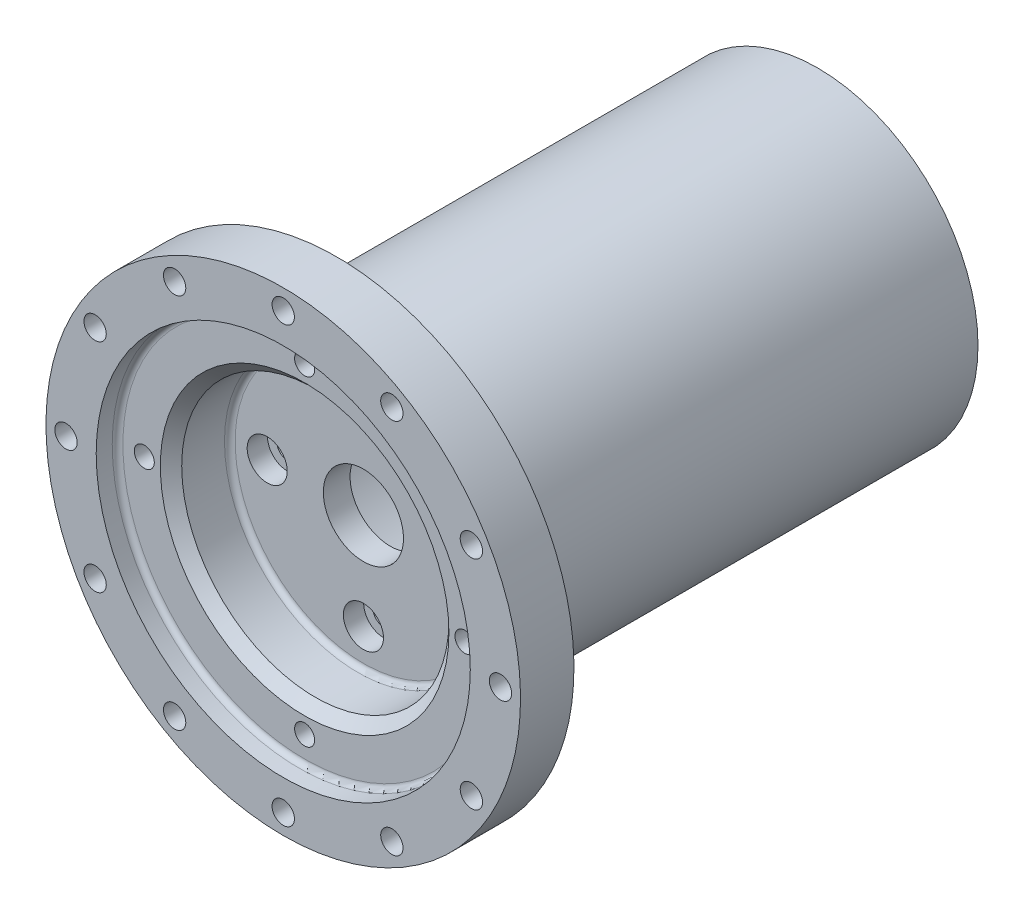
from build123d import *

# Parameters (mm, degrees)
SKETCH2_R                                       = 31.75
CUT_EXTRUDE1_DEPTH                              = 101.6
SKETCH3_R                                       = 31.75
CUT_EXTRUDE2_DEPTH                              = 19.05
SKETCH4_R                                       = 9.525
CUT_EXTRUDE3_DEPTH                              = 108.95
SKETCH5_R                                       = 44.45
CUT_EXTRUDE4_DEPTH                              = 5.08
FILLET1_R                                       = 1.27
FILLET2_R                                       = 6.35
CHAMFER1_SIZE                                   = 2.54
CBORE_FOR_10_SOCKET_HEAD_CAP_SCREW1_D           = 5.1054
CBORE_FOR_10_SOCKET_HEAD_CAP_SCREW1_CBORE_D     = 9.525
CBORE_FOR_10_SOCKET_HEAD_CAP_SCREW1_CBORE_DEPTH = 4.826
F_3_16_0_1875_DIAMETER_HOLE1_D                  = 4.7625
F_3_16_0_1875_DIAMETER_HOLE1_DEPTH              = 6.35
F_3_16_0_1875_DIAMETER_HOLE1_TIP                = 1.430799349
F_4_0_209_DIAMETER_HOLE1_D                      = 5.3086


with BuildPart() as part:
    # Sketch1 → Revolve1 (revolve)
    with BuildSketch(Plane(origin=(0, 0, 0), x_dir=(0, 0, -1), z_dir=(1, 0, 0))):
        Polygon((-63.5, 0), (63.5, 0), (63.5, 38.1), (-50.8, 38.1), (-50.8, 56.388), (-63.5, 56.388), align=None)
    revolve(axis=Axis((0, 0, 63.5), (0, 0, -1)))

    # Sketch2 → Cut-Extrude1 (cut)
    with BuildSketch(Plane(origin=(0, 0, -63.5), x_dir=(-1, 0, 0), z_dir=(0, 0, -1))):
        Circle(SKETCH2_R)
    extrude(amount=-CUT_EXTRUDE1_DEPTH, mode=Mode.SUBTRACT)

    # Sketch3 → Cut-Extrude2 (cut)
    with BuildSketch(Plane.XY.offset(63.5)):
        Circle(SKETCH3_R)
    extrude(amount=-CUT_EXTRUDE2_DEPTH, mode=Mode.SUBTRACT)

    # Sketch4 → Cut-Extrude3 (cut, through all)
    with BuildSketch(Plane.XY.offset(44.45)):
        Circle(SKETCH4_R)
    extrude(amount=-CUT_EXTRUDE3_DEPTH, mode=Mode.SUBTRACT)

    # Sketch5 → Cut-Extrude4 (cut)
    with BuildSketch(Plane.XY.offset(63.5)):
        Circle(SKETCH5_R)
    extrude(amount=-CUT_EXTRUDE4_DEPTH, mode=Mode.SUBTRACT)

    # Fillet1
    fillet1_edges = [part.edges().sort_by_distance(p)[0] for p in [
        (31.75, 0, 38.1),
        (-31.75, 0, 44.45),
        (-44.45, 0, 58.42),
    ]]
    fillet(fillet1_edges, radius=FILLET1_R)

    # Fillet2
    fillet2_edges = [part.edges().sort_by_distance(p)[0] for p in [
        (0, -38.1, 50.8),
    ]]
    fillet(fillet2_edges, radius=FILLET2_R)

    # Chamfer1
    chamfer1_edges = [part.edges().sort_by_distance(p)[0] for p in [
        (-31.75, 0, 58.42),
    ]]
    chamfer(chamfer1_edges, length=CHAMFER1_SIZE)

    # CBORE for #10 Socket Head Cap Screw1 (through all)
    with Locations(Plane.XY.offset(44.45)):
        with Locations((0, 22.86), (22.86, 0), (0, -22.86), (-22.86, 0)):
            CounterBoreHole(CBORE_FOR_10_SOCKET_HEAD_CAP_SCREW1_D / 2, CBORE_FOR_10_SOCKET_HEAD_CAP_SCREW1_CBORE_D / 2, CBORE_FOR_10_SOCKET_HEAD_CAP_SCREW1_CBORE_DEPTH)

    # 3/16 (0.1875) Diameter Hole1
    with Locations(Plane.XY.offset(58.42)):
        with Locations((0, 38.1), (38.1, 0), (0, -38.1), (-38.1, 0), (0, 0)):
            Hole(F_3_16_0_1875_DIAMETER_HOLE1_D / 2, depth=F_3_16_0_1875_DIAMETER_HOLE1_DEPTH)
            with Locations((0, 0, -(F_3_16_0_1875_DIAMETER_HOLE1_DEPTH + F_3_16_0_1875_DIAMETER_HOLE1_TIP / 2))):  # 118° drill point
                Cone(0, F_3_16_0_1875_DIAMETER_HOLE1_D / 2, F_3_16_0_1875_DIAMETER_HOLE1_TIP, mode=Mode.SUBTRACT)

    # #4 (0.209) Diameter Hole1 (through all)
    with Locations(Plane.XY.offset(63.5)):
        with Locations((0, 51.6255), (25.81275, 44.708994483), (44.708994483, 25.81275), (51.6255, 0), (44.708994483, -25.81275), (25.81275, -44.708994483), (0, -51.6255), (-25.81275, -44.708994483), (-44.708994483, -25.81275), (-51.6255, 0), (-44.708994483, 25.81275), (-25.81275, 44.708994483), (0, 0)):
            Hole(F_4_0_209_DIAMETER_HOLE1_D / 2)


solid = part.part
